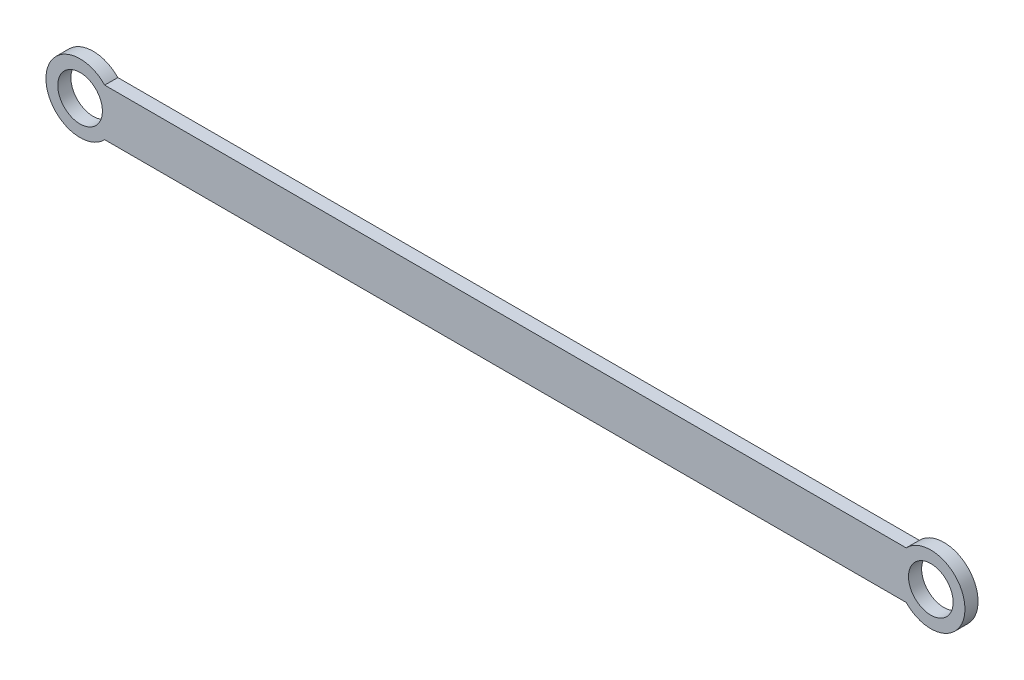
from build123d import *

# Parameters (mm, degrees)
SKETCH_1_R      = 4.25
EXTRUDE_1_DEPTH = 2.5


with BuildPart() as part:
    # 草图1 → 凸台-拉伸1 (new body)
    with BuildSketch(Plane.XY):
        with BuildLine():
            Line((4.69041576, 4.5), (157.30958424, 4.5))
            ThreePointArc((157.30958424, 4.5), (168.5, 0), (157.30958424, -4.5))
            Line((157.30958424, -4.5), (4.69041576, -4.5))
            ThreePointArc((4.69041576, -4.5), (-6.5, 0), (4.69041576, 4.5))
        make_face()
        Circle(SKETCH_1_R, mode=Mode.SUBTRACT)
        with Locations((162, 0)):
            Circle(SKETCH_1_R, mode=Mode.SUBTRACT)
    extrude(amount=EXTRUDE_1_DEPTH)


solid = part.part
